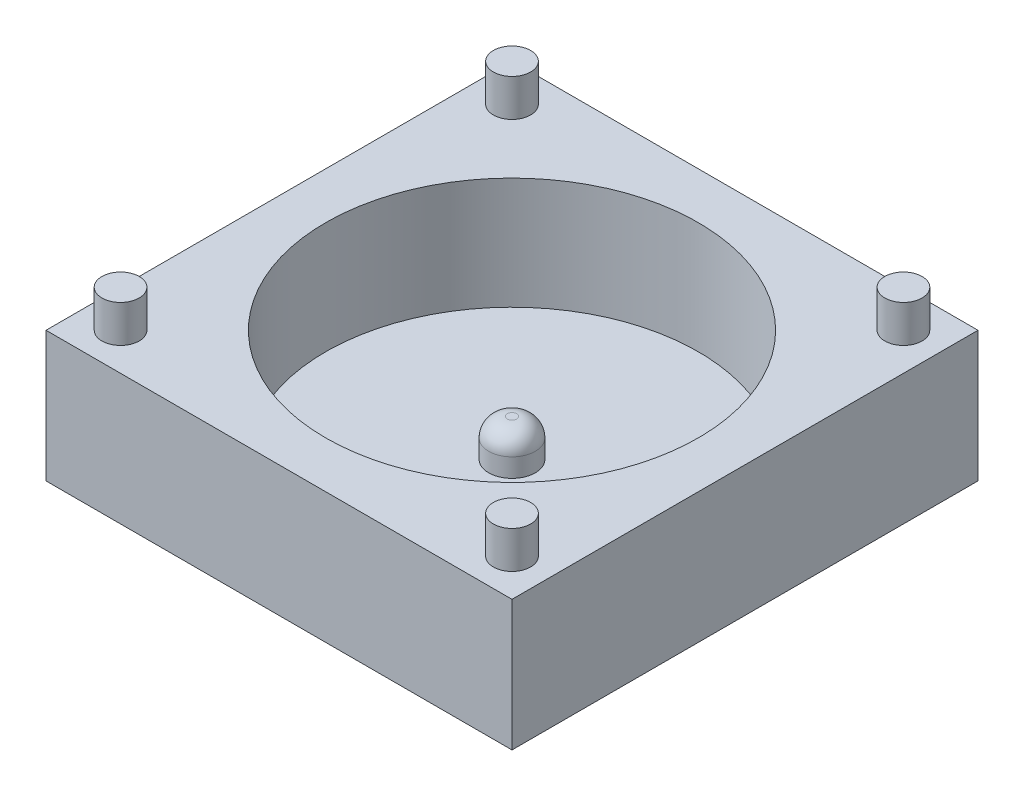
from build123d import *

# Parameters (mm, degrees)
SKETCH1_W           = 25
SKETCH1_H           = 25
BOSS_EXTRUDE1_DEPTH = 7
SKETCH2_R           = 10
CUT_EXTRUDE1_DEPTH  = 6
SKETCH3_R           = 1.25
BOSS_EXTRUDE2_DEPTH = 2
FILLET1_R           = 1
SKETCH4_R           = 1
BOSS_EXTRUDE3_DEPTH = 2


with BuildPart() as part:
    # Sketch1 → Boss-Extrude1 (new body)
    with BuildSketch(Plane(origin=(0, 0, 0), x_dir=(1, 0, 0), z_dir=(0, 1, 0))):
        Rectangle(SKETCH1_W, SKETCH1_H)
    extrude(amount=BOSS_EXTRUDE1_DEPTH)

    # Sketch2 → Cut-Extrude1 (cut)
    with BuildSketch(Plane(origin=(0, 7, 0), x_dir=(1, 0, 0), z_dir=(0, 1, 0))):
        Circle(SKETCH2_R)
    extrude(amount=-CUT_EXTRUDE1_DEPTH, mode=Mode.SUBTRACT)

    # Sketch3 → Boss-Extrude2 (add)
    with BuildSketch(Plane(origin=(0, 1, 0), x_dir=(1, 0, 0), z_dir=(0, 1, 0))):
        Circle(SKETCH3_R)
    extrude(amount=BOSS_EXTRUDE2_DEPTH)

    # Fillet1
    fillet1_edges = [part.edges().sort_by_distance(p)[0] for p in [
        (-1.25, 3, 0),
    ]]
    fillet(fillet1_edges, radius=FILLET1_R)

    # Sketch4 → Boss-Extrude3 (add)
    with BuildSketch(Plane(origin=(0, 7, 0), x_dir=(1, 0, 0), z_dir=(0, 1, 0))):
        with Locations((-10.5, 10.5)):
            Circle(SKETCH4_R)
        with Locations((10.5, 10.5)):
            Circle(SKETCH4_R)
        with Locations((10.5, -10.5)):
            Circle(SKETCH4_R)
        with Locations((-10.5, -10.5)):
            Circle(SKETCH4_R)
    extrude(amount=BOSS_EXTRUDE3_DEPTH)


solid = part.part
